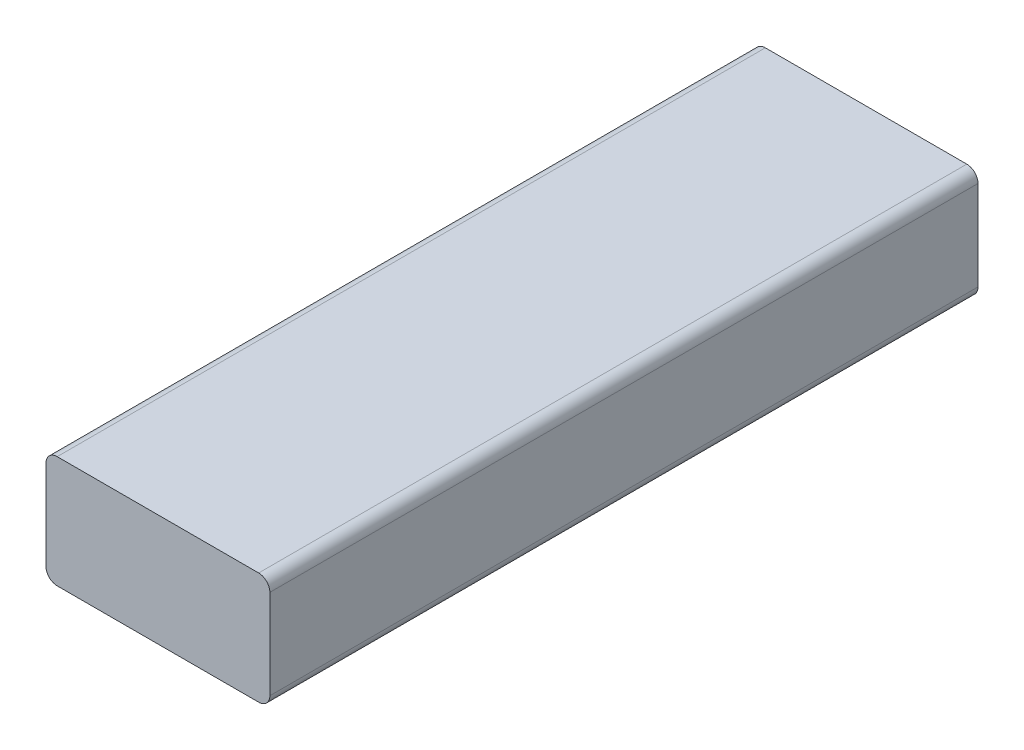
from build123d import *

# Parameters (mm, degrees)
SKETCH1_W           = 101.6
SKETCH1_H           = 321.4
BOSS_EXTRUDE1_DEPTH = 50.8
FILLET1_R           = 5.08


with BuildPart() as part:
    # Sketch1 → Boss-Extrude1 (new body)
    with BuildSketch(Plane(origin=(0, -12.7, 0), x_dir=(-1, 0, 0), z_dir=(0, -1, 0))):
        with Locations((-1863.5, 0)):
            Rectangle(SKETCH1_W, SKETCH1_H)
    extrude(amount=-BOSS_EXTRUDE1_DEPTH)

    # Fillet1
    fillet1_edges = [part.edges().sort_by_distance(p)[0] for p in [
        (1812.7, 38.1, 0),
        (1914.3, 38.1, 0),
        (1812.7, -12.7, 0),
        (1914.3, -12.7, 0),
    ]]
    fillet(fillet1_edges, radius=FILLET1_R)


solid = part.part
